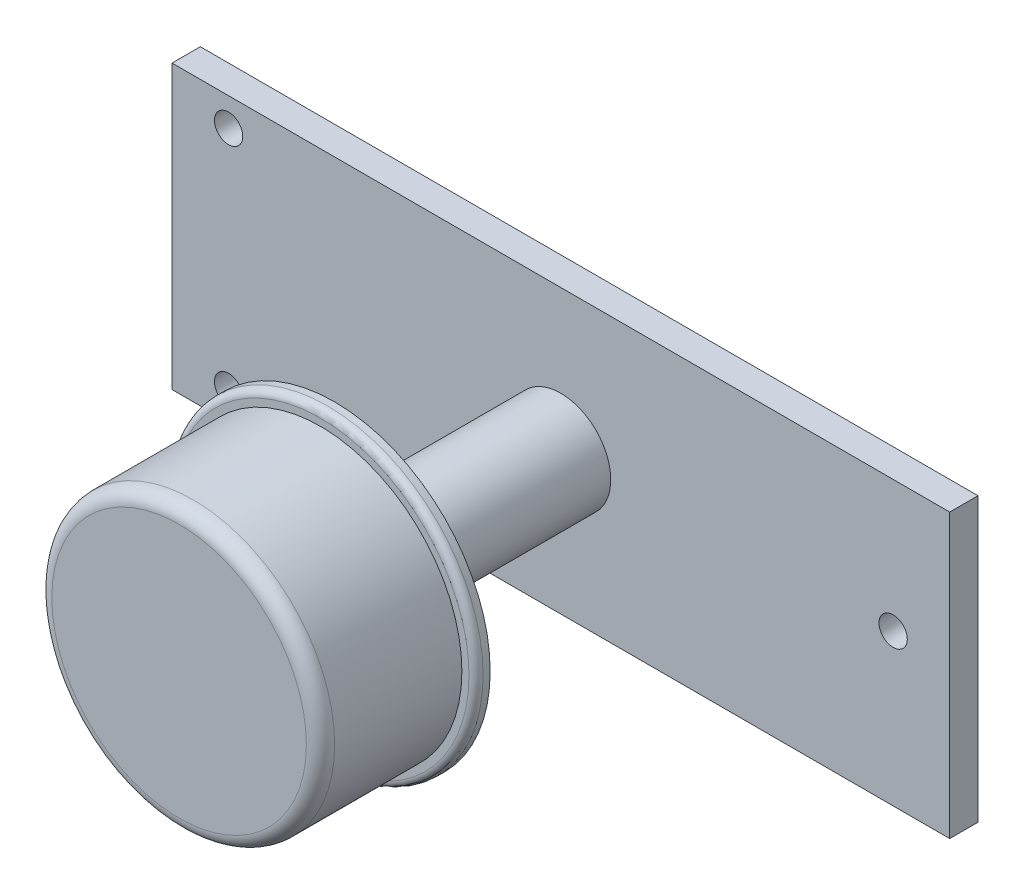
from build123d import *

# Parameters (mm, degrees)
SKETCH1_W           = 55
SKETCH1_H           = 20
SKETCH1_R           = 1
BOSS_EXTRUDE1_DEPTH = 2
SKETCH2_R           = 3.526621479
BOSS_EXTRUDE2_DEPTH = 16
SKETCH3_R           = 11
BOSS_EXTRUDE3_DEPTH = 1
SKETCH5_R           = 10
BOSS_EXTRUDE4_DEPTH = 10
FILLET1_R           = 1
FILLET2_R           = 0.5


with BuildPart() as part:
    # Sketch1 → Boss-Extrude1 (new body)
    with BuildSketch(Plane.XY):
        with Locations((27.5, 10)):
            Rectangle(SKETCH1_W, SKETCH1_H)
        with Locations((4, 18)):
            Circle(SKETCH1_R, mode=Mode.SUBTRACT)
        with Locations((4, 2)):
            Circle(SKETCH1_R, mode=Mode.SUBTRACT)
        with Locations((51, 10.710900474)):
            Circle(SKETCH1_R, mode=Mode.SUBTRACT)
    extrude(amount=BOSS_EXTRUDE1_DEPTH)

    # Sketch2 → Boss-Extrude2 (add)
    with BuildSketch(Plane.XY.offset(2)):
        with Locations((27.5, 10)):
            Circle(SKETCH2_R)
    extrude(amount=BOSS_EXTRUDE2_DEPTH)

    # Sketch3 → Boss-Extrude3 (add)
    with BuildSketch(Plane.XY.offset(18)):
        with Locations((27.5, 10)):
            Circle(SKETCH3_R)
    extrude(amount=BOSS_EXTRUDE3_DEPTH)

    # Sketch5 → Boss-Extrude4 (add)
    with BuildSketch(Plane.XY.offset(19)):
        with Locations((27.5, 10)):
            Circle(SKETCH5_R)
    extrude(amount=BOSS_EXTRUDE4_DEPTH)

    # Fillet1
    fillet1_edges = [part.edges().sort_by_distance(p)[0] for p in [
        (17.5, 10, 29),
    ]]
    fillet(fillet1_edges, radius=FILLET1_R)

    # Fillet2
    fillet2_edges = [part.edges().sort_by_distance(p)[0] for p in [
        (16.5, 10, 19),
    ]]
    fillet(fillet2_edges, radius=FILLET2_R)


solid = part.part
